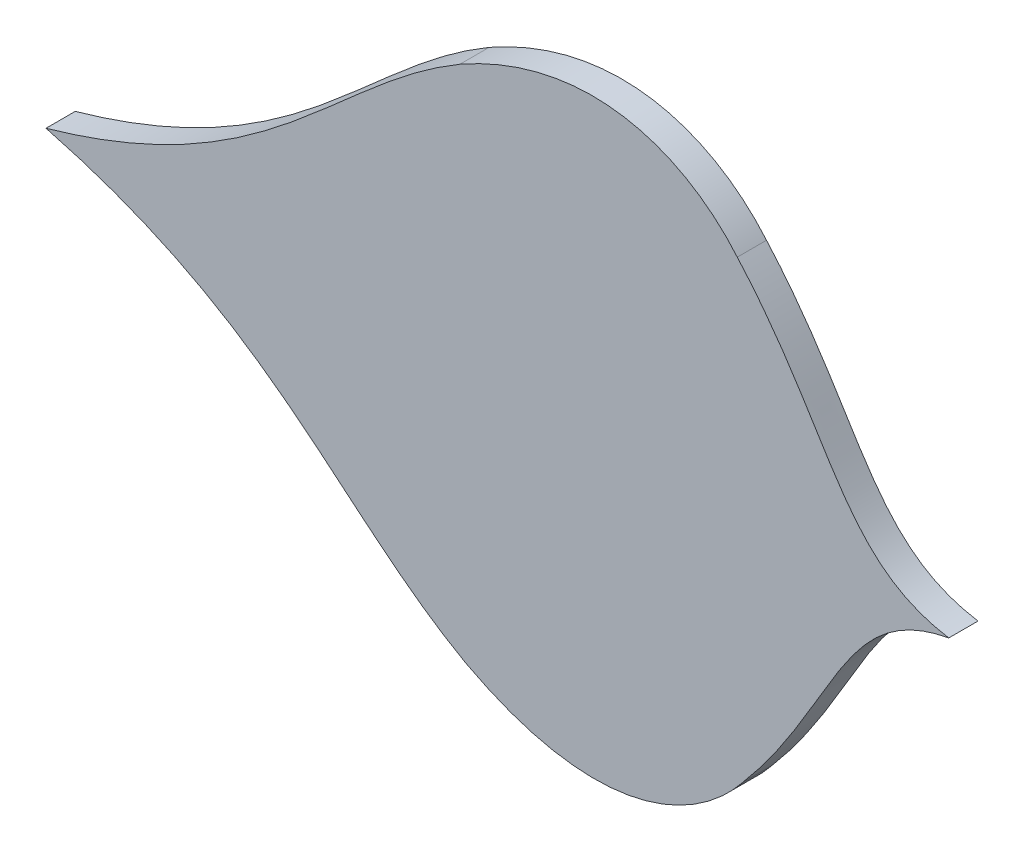
from build123d import *

# Parameters (mm, degrees)
BOSS_EXTRUDE1_DEPTH = 10


with BuildPart() as part:
    # Sketch1 → Boss-Extrude1 (new body)
    with BuildSketch(Plane.XY):
        with BuildLine():
            add(Edge.make_bspline(
                [(1416.340963062, 760.768025017), (1379.688076891, 766.677060222), (1376.796284846, 800.788187242), (1343.96405584, 837.42855153)],
                knots=[0, 0, 0, 0, 1, 1, 1, 1], degree=3))
            add(Edge.make_bspline(
                [(1343.96405584, 837.42855153), (1328.166228106, 856.300178667), (1295.277231091, 873.15146474), (1249.074337277, 847.16233697)],
                knots=[0, 0, 0, 0, 1, 1, 1, 1], degree=3))
            add(Edge.make_bspline(
                [(1249.074337277, 847.16233697), (1205.448911361, 821.536040114), (1185.29886025, 779.453471672), (1107.416163396, 757.35449132)],
                knots=[0, 0, 0, 0, 1, 1, 1, 1], degree=3))
            add(Edge.make_bspline(
                [(1251.024211071, 670.698758614), (1206.843179005, 695.354818366), (1185.768159813, 736.981861169), (1107.416163396, 757.35449132)],
                knots=[0, 0, 0, 0, 1, 1, 1, 1], degree=3))
            add(Edge.make_bspline(
                [(1345.675676059, 682.526921773), (1330.298707188, 663.310821746), (1297.790099097, 645.736910201), (1251.024211071, 670.698758614)],
                knots=[0, 0, 0, 0, 1, 1, 1, 1], degree=3))
            add(Edge.make_bspline(
                [(1416.340963062, 760.768025017), (1379.82759664, 754.050522934), (1377.690255695, 719.883825383), (1345.675676059, 682.526921773)],
                knots=[0, 0, 0, 0, 1, 1, 1, 1], degree=3))
        make_face()
    extrude(amount=BOSS_EXTRUDE1_DEPTH)


solid = part.part
